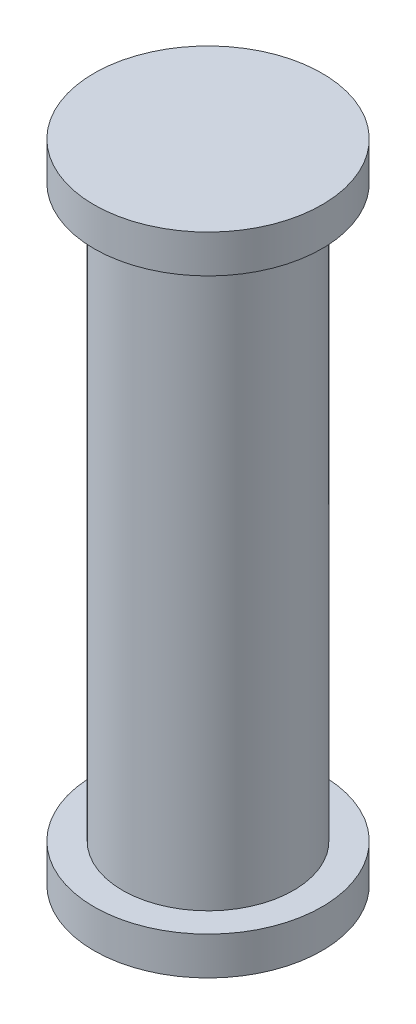
from build123d import *

# Parameters (mm, degrees)
SKETCH1_R           = 4.5
BOSS_EXTRUDE1_DEPTH = 30
SKETCH2_R           = 6
BOSS_EXTRUDE2_DEPTH = 2
SKETCH3_R           = 6
BOSS_EXTRUDE3_DEPTH = 2


with BuildPart() as part:
    # Sketch1 → Boss-Extrude1 (new body)
    with BuildSketch(Plane(origin=(0, 0, 0), x_dir=(1, 0, 0), z_dir=(0, 1, 0))):
        Circle(SKETCH1_R)
    extrude(amount=BOSS_EXTRUDE1_DEPTH)

    # Sketch2 → Boss-Extrude2 (add)
    with BuildSketch(Plane(origin=(0, 0, 0), x_dir=(1, 0, 0), z_dir=(0, 1, 0))):
        Circle(SKETCH2_R)
    extrude(amount=-BOSS_EXTRUDE2_DEPTH)

    # Sketch3 → Boss-Extrude3 (add)
    with BuildSketch(Plane(origin=(0, 30, 0), x_dir=(1, 0, 0), z_dir=(0, 1, 0))):
        Circle(SKETCH3_R)
    extrude(amount=BOSS_EXTRUDE3_DEPTH)


solid = part.part
